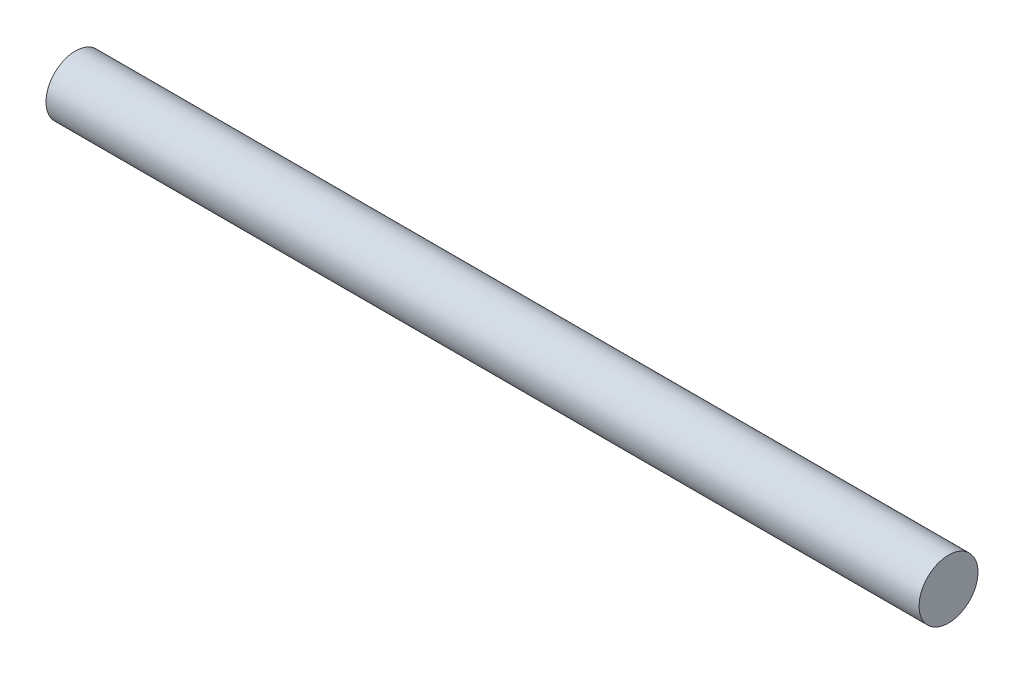
from build123d import *

# Parameters (mm, degrees)
SKETCH1_R           = 6
BOSS_EXTRUDE1_DEPTH = 177.8


with BuildPart() as part:
    # Sketch1 → Boss-Extrude1 (new body)
    with BuildSketch(Plane(origin=(0, 0, 0), x_dir=(0, 0, -1), z_dir=(1, 0, 0))):
        Circle(SKETCH1_R)
    extrude(amount=BOSS_EXTRUDE1_DEPTH)


solid = part.part
